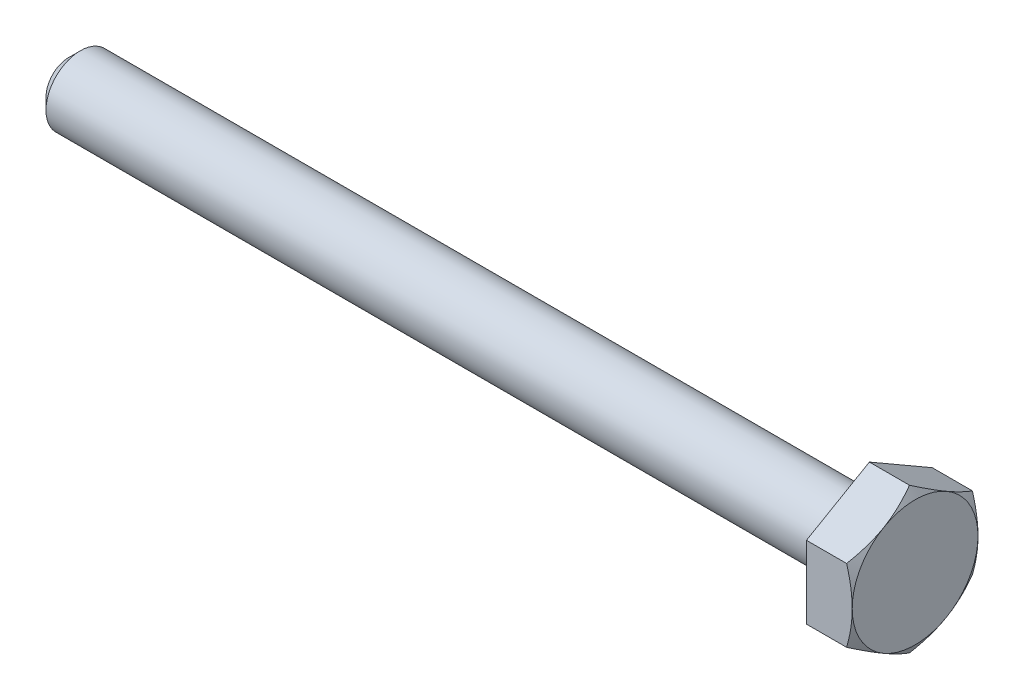
from build123d import *

# Parameters (mm, degrees)
DODANIE_WYCI_GNI_CIE1_DEPTH = 2
SFAZOWANIE1_SIZE            = 0.5


with BuildPart() as part:
    # Szkic1 → Obrót1 (revolve)
    with BuildSketch(Plane.XY):
        Polygon((0, 0), (0, 2.75), (-2, 2.75), (-2, 1.5), (-37, 1.5), (-37, 0), align=None)
    revolve(axis=Axis((-37, 0, 0), (1, 0, 0)))

    # Szkic2 → Dodanie-wyciągnięcie1 (add)
    with BuildSketch(Plane(origin=(0, 0, 0), x_dir=(0, 0, -1), z_dir=(1, 0, 0))):
        Polygon((-2.75, 1.58771324), (-2.75, -1.58771324), (0, -3.175426481), (2.75, -1.58771324), (2.75, 1.58771324), (0, 3.175426481), align=None)
    extrude(amount=-DODANIE_WYCI_GNI_CIE1_DEPTH)

    # Sfazowanie1
    sfazowanie1_edges = [part.edges().sort_by_distance(p)[0] for p in [
        (-37, -1.5, 0),
    ]]
    chamfer(sfazowanie1_edges, length=SFAZOWANIE1_SIZE)

    # Szkic9 → Wycięcie-obrót1 (revolve, cut)
    with BuildSketch(Plane.XY):
        Polygon((0, 3.175426481), (0, 2.75), (-0.245620093, 3.175426481), align=None)
    revolve(axis=Axis((-37, 0, 0), (1, 0, 0)), mode=Mode.SUBTRACT)


solid = part.part
